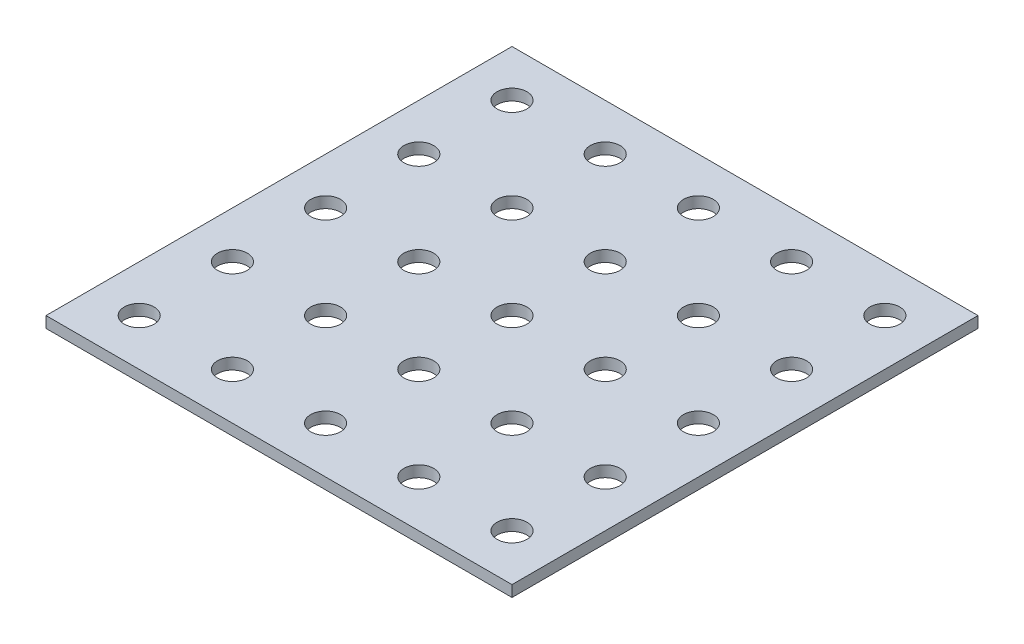
from build123d import *

# Parameters (mm, degrees)
SKETCH_1_W          = 250
SKETCH_1_H          = 250
EXTRUDE_1_DEPTH     = 6
SKETCH_2_R          = 8
CUT_EXTRUDE_1_DEPTH = 6


with BuildPart() as part:
    # Эскиз1 → Бобышка-Вытянуть1 (new body)
    with BuildSketch(Plane(origin=(0, 0, 0), x_dir=(1, 0, 0), z_dir=(0, 1, 0))):
        Rectangle(SKETCH_1_W, SKETCH_1_H)
    extrude(amount=EXTRUDE_1_DEPTH)

    # Эскиз2 → Вырез-Вытянуть1 (cut)
    with BuildSketch(Plane(origin=(0, 6, 0), x_dir=(1, 0, 0), z_dir=(0, 1, 0))):
        with Locations((-100, -100)):
            Circle(SKETCH_2_R)
        with Locations((-50, -100)):
            Circle(SKETCH_2_R)
        with Locations((0, -100)):
            Circle(SKETCH_2_R)
        with Locations((50, -100)):
            Circle(SKETCH_2_R)
        with Locations((100, -100)):
            Circle(SKETCH_2_R)
        with Locations((-50, -50)):
            Circle(SKETCH_2_R)
        with Locations((0, -50)):
            Circle(SKETCH_2_R)
        with Locations((50, -50)):
            Circle(SKETCH_2_R)
        with Locations((100, -50)):
            Circle(SKETCH_2_R)
        with Locations((-50, 0)):
            Circle(SKETCH_2_R)
        Circle(SKETCH_2_R)
        with Locations((50, 0)):
            Circle(SKETCH_2_R)
        with Locations((100, 0)):
            Circle(SKETCH_2_R)
        with Locations((-50, 50)):
            Circle(SKETCH_2_R)
        with Locations((0, 50)):
            Circle(SKETCH_2_R)
        with Locations((50, 50)):
            Circle(SKETCH_2_R)
        with Locations((100, 50)):
            Circle(SKETCH_2_R)
        with Locations((-50, 100)):
            Circle(SKETCH_2_R)
        with Locations((0, 100)):
            Circle(SKETCH_2_R)
        with Locations((50, 100)):
            Circle(SKETCH_2_R)
        with Locations((100, 100)):
            Circle(SKETCH_2_R)
        with Locations((-100, -50)):
            Circle(SKETCH_2_R)
        with Locations((-100, 0)):
            Circle(SKETCH_2_R)
        with Locations((-100, 50)):
            Circle(SKETCH_2_R)
        with Locations((-100, 100)):
            Circle(SKETCH_2_R)
    extrude(amount=-CUT_EXTRUDE_1_DEPTH, mode=Mode.SUBTRACT)


solid = part.part
